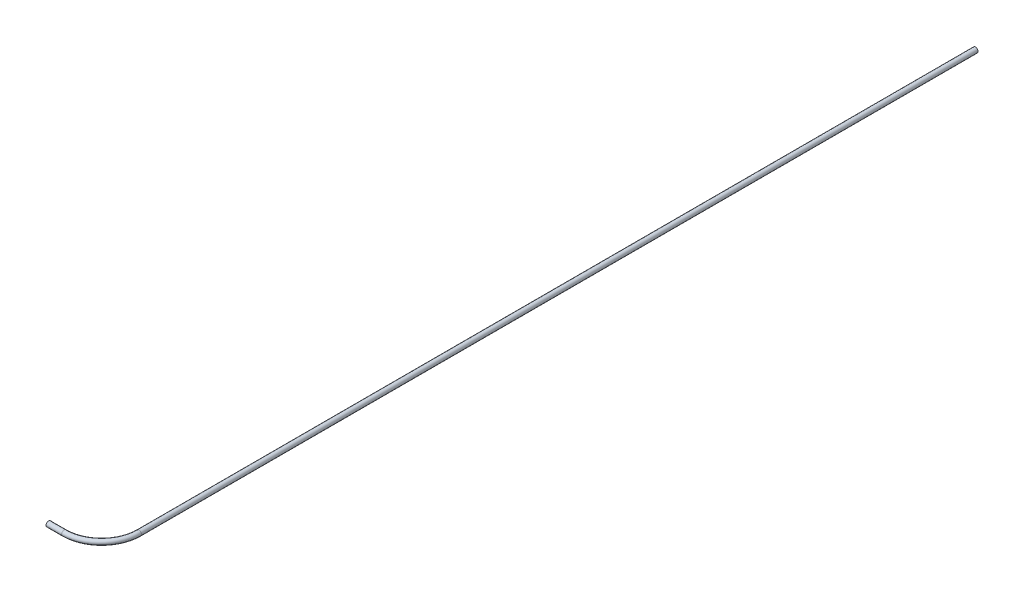
from build123d import *

# Parameters (mm, degrees)
SKETCH2_R   = 2.38125
SKETCH2_R_2 = 1.82245


with BuildPart() as part:
    # Sweep1: sweep along a path in Sketch1
    with BuildLine(Plane(origin=(0, 0, 0), x_dir=(1, 0, 0), z_dir=(0, 1, 0))) as sweep1_path:
        Line((49.521745, 815.975), (49.521745, 34.925))
        ThreePointArc((49.521745, 34.925), (39.292449333, 10.229295667), (14.596745, 0))
        Line((14.596745, 0), (0, 0))
    # Sketch2 → Sweep1 (sweep)
    with BuildSketch(Plane(origin=(0, 0, 0), x_dir=(0, 0, -1), z_dir=(1, 0, 0))):
        Circle(SKETCH2_R)
        Circle(SKETCH2_R_2, mode=Mode.SUBTRACT)
    sweep(path=sweep1_path.line)


solid = part.part
